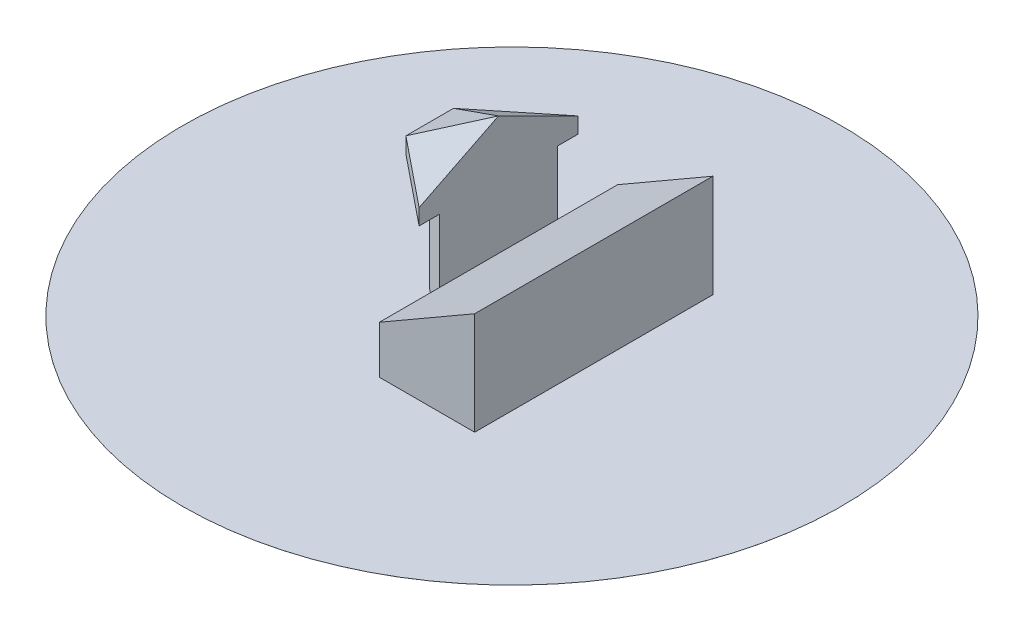
from build123d import *

# Parameters (mm, degrees)
EXTRUDE1_DEPTH = 75
EXTRUDE2_DEPTH = 70
EXTRUDE3_DEPTH = 10
SKETCH6_R      = 207.5
EXTRUDE4_DEPTH = 0.01


with BuildPart() as part:
    # Sketch1 → Extrude1 (new body, symmetric)
    with BuildSketch(Plane.XY):
        Polygon((0, 0), (0, 30), (60, 64.641016151), (60, 0), align=None)
    extrude(amount=EXTRUDE1_DEPTH, both=True)

    # Sketch2 → Extrude2 (add)
    with BuildSketch(Plane(origin=(0, 0, 0), x_dir=(1, 0, 0), z_dir=(0, 1, 0))):
        Polygon((0, 37.141798985), (-33.301270189, 10.224702754), (-33.301270189, -10.224702754), (0, -37.141798985), align=None)
    extrude(amount=EXTRUDE2_DEPTH)

    # Sketch3 → Extrude3 (add)
    with BuildSketch(Plane(origin=(0, 70, 0), x_dir=(-1, 0, 0), z_dir=(0, 1, 0))):
        Polygon((0, -50), (43.301270189, -15), (43.301270189, 15), (0, 50), align=None)
    extrude(amount=EXTRUDE3_DEPTH)

    # Sketch4 → Loft1 section 0
    with BuildSketch(Plane(origin=(0, 80, 0), x_dir=(-1, 0, 0), z_dir=(0, 1, 0)), mode=Mode.PRIVATE) as loft1_s0:
        Polygon((0, -50), (43.301270189, -15), (43.301270189, 15), (0, 50), align=None)
    loft([loft1_s0.sketch, Vertex(0, 105, 0)])

    # Sketch6 → Extrude4 (add)
    with BuildSketch(Plane(origin=(0, 0, 0), x_dir=(1, 0, 0), z_dir=(0, 1, 0))):
        with Locations(Location((8.349364905, 0.109485549, 0), (0, 0, 270))):  # turned: the seam where the file's is
            Circle(SKETCH6_R)
    extrude(amount=EXTRUDE4_DEPTH)


solid = part.part
